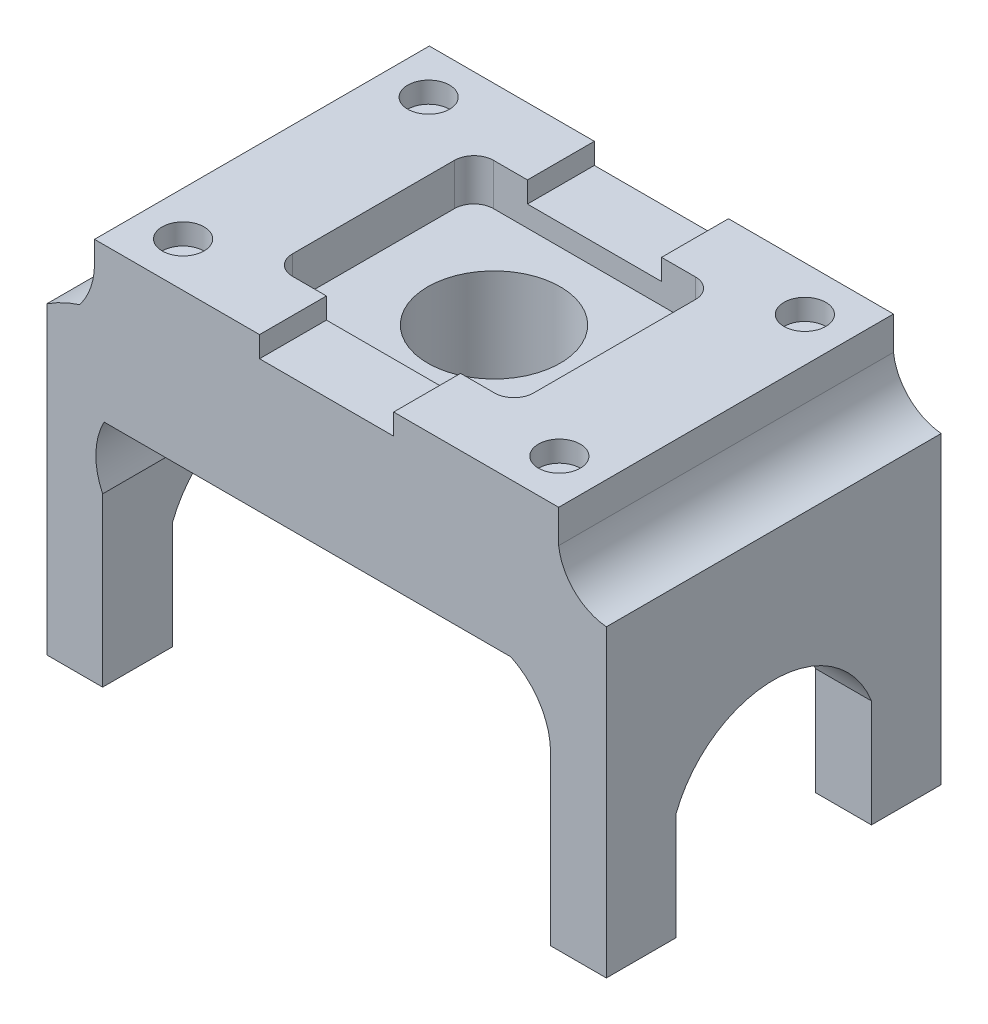
from build123d import *

# Parameters (mm, degrees)
BOSS_EXTRUDE1_DEPTH     = 60.96
SKETCH4_R               = 12.065
CUT_EXTRUDE3_DEPTH      = 3.81
CUT_EXTRUDE4_DEPTH      = 1
CUT_EXTRUDE4_DEPTH_BACK = 102.872142857
SKETCH7_R               = 3.81
BOSS_EXTRUDE3_DEPTH     = 3.81
CUT_EXTRUDE7_DEPTH      = 3.81
SKETCH11_R              = 12.065
CUT_EXTRUDE8_DEPTH      = 114.3


with BuildPart() as part:
    # Sketch1 → Boss-Extrude1 (new body)
    with BuildSketch(Plane.XY):
        with BuildLine():
            Line((40.776071429, -15.784285714), (40.776071429, 14.695714286))
            ThreePointArc((40.776071429, 14.695714286), (38.819326582, 21.468636013), (33.552060607, 26.154490072))
            Line((33.552060607, 26.154490072), (-40.503928571, 26.154490072))
            ThreePointArc((-40.503928571, 26.154490072), (-42.006230477, 20.457549787), (-40.776071429, 14.695714286))
            Line((-40.776071429, 14.695714286), (-40.776071429, -15.784285714))
            Line((-40.776071429, -15.784285714), (-50.936071429, -15.784285714))
            Line((-50.936071429, -15.784285714), (-50.936071429, 39.587714286))
            ThreePointArc((-50.936071429, 39.587714286), (-48.041649354, 41.212124157), (-44.960126074, 42.445250611))
            ThreePointArc((-44.960126074, 42.445250611), (-42.948064089, 46.137564922), (-42.251938956, 50.284490072))
            Line((-42.251938956, 50.284490072), (-29.309810678, 50.284490072))
            Line((-29.309810678, 50.284490072), (29.309810678, 50.284490072))
            Line((29.309810678, 50.284490072), (42.251938956, 50.284490072))
            Line((42.251938956, 50.284490072), (42.251938956, 48.042823233))
            ThreePointArc((42.251938956, 48.042823233), (45.101391865, 42.282225017), (50.936071429, 39.587714286))
            Line((50.936071429, 39.587714286), (50.936071429, -15.784285714))
            Line((50.936071429, -15.784285714), (40.776071429, -15.784285714))
        make_face()
    extrude(amount=BOSS_EXTRUDE1_DEPTH)

    # Sketch4 → Cut-Extrude3 (cut)
    with BuildSketch(Plane(origin=(0, 46.474490072, 0), x_dir=(1, 0, 0), z_dir=(0, 1, 0))):
        with Locations((0, -30.48)):
            Circle(SKETCH4_R)
    extrude(amount=-CUT_EXTRUDE3_DEPTH, mode=Mode.SUBTRACT)

    # Sketch6 → Cut-Extrude4 (cut, two sides)
    with BuildSketch(Plane(origin=(50.936071429, 0, 0), x_dir=(0, 0, -1), z_dir=(1, 0, 0))) as cut_extrude4_sk:
        with BuildLine():
            Line((-48.26, 3.773714286), (-48.26, -15.784285714))
            Line((-48.26, -15.784285714), (-12.7, -15.784285714))
            Line((-12.7, -15.784285714), (-12.7, 3.773714286))
            ThreePointArc((-12.7, 3.773714286), (-30.48, 15.984554981), (-48.26, 3.773714286))
        make_face()
    extrude(amount=CUT_EXTRUDE4_DEPTH, mode=Mode.SUBTRACT)
    extrude(cut_extrude4_sk.sketch, amount=-CUT_EXTRUDE4_DEPTH_BACK, mode=Mode.SUBTRACT)

    # Sketch7 → Boss-Extrude3 (add)
    with BuildSketch(Plane(origin=(0, 50.284490072, 0), x_dir=(1, 0, 0), z_dir=(0, 1, 0))):
        with BuildLine():
            Line((-12.20867372, -12.182150361), (-12.20867372, 0))
            Line((-12.20867372, 0), (-42.251938956, 0))
            Line((-42.251938956, 0), (-42.251938956, -60.96))
            Line((-42.251938956, -60.96), (-12.20867372, -60.96))
            Line((-12.20867372, -60.96), (-12.20867372, -48.777849639))
            Line((-12.20867372, -48.777849639), (-18.390263021, -48.777849639))
            ThreePointArc((-18.390263021, -48.777849639), (-20.904734735, -47.736321353), (-21.946263021, -45.221849639))
            Line((-21.946263021, -45.221849639), (-21.946263021, -15.738150361))
            ThreePointArc((-21.946263021, -15.738150361), (-20.904734735, -13.223678647), (-18.390263021, -12.182150361))
            Line((-18.390263021, -12.182150361), (-12.20867372, -12.182150361))
        make_face()
        with Locations((-34.250938956, -52.832)):
            Circle(SKETCH7_R, mode=Mode.SUBTRACT)
        with Locations((-34.250938956, -8.128)):
            Circle(SKETCH7_R, mode=Mode.SUBTRACT)
        with BuildLine():
            Line((42.251938956, 0), (12.20867372, 0))
            Line((12.20867372, 0), (12.20867372, -12.182150361))
            Line((12.20867372, -12.182150361), (18.390263021, -12.182150361))
            ThreePointArc((18.390263021, -12.182150361), (20.904734735, -13.223678647), (21.946263021, -15.738150361))
            Line((21.946263021, -15.738150361), (21.946263021, -45.221849639))
            ThreePointArc((21.946263021, -45.221849639), (20.904734735, -47.736321353), (18.390263021, -48.777849639))
            Line((18.390263021, -48.777849639), (12.20867372, -48.777849639))
            Line((12.20867372, -48.777849639), (12.20867372, -60.96))
            Line((12.20867372, -60.96), (42.251938956, -60.96))
            Line((42.251938956, -60.96), (42.251938956, 0))
        make_face()
        with Locations((34.250938956, -52.832)):
            Circle(SKETCH7_R, mode=Mode.SUBTRACT)
        with Locations((34.250938956, -8.128)):
            Circle(SKETCH7_R, mode=Mode.SUBTRACT)
    extrude(amount=BOSS_EXTRUDE3_DEPTH)

    # Sketch8 → Cut-Extrude7 (cut)
    with BuildSketch(Plane(origin=(0, 50.284490072, 0), x_dir=(1, 0, 0), z_dir=(0, 1, 0))):
        Polygon((-12.20867372, -12.182150361), (-18.390263021, -12.182150361), (-18.390263021, -48.777849639), (-12.20867372, -48.777849639), (12.20867372, -48.777849639), (18.390263021, -48.777849639), (18.390263021, -12.182150361), (12.20867372, -12.182150361), align=None)
        with BuildLine():
            Line((-18.390263021, -12.182150361), (-18.390263021, -48.777849639))
            ThreePointArc((-18.390263021, -48.777849639), (-20.904734735, -47.736321353), (-21.946263021, -45.221849639))
            Line((-21.946263021, -45.221849639), (-21.946263021, -15.738150361))
            ThreePointArc((-21.946263021, -15.738150361), (-20.904734735, -13.223678647), (-18.390263021, -12.182150361))
        make_face()
        with BuildLine():
            Line((18.390263021, -12.182150361), (18.390263021, -48.777849639))
            ThreePointArc((18.390263021, -48.777849639), (20.904734735, -47.736321353), (21.946263021, -45.221849639))
            Line((21.946263021, -45.221849639), (21.946263021, -15.738150361))
            ThreePointArc((21.946263021, -15.738150361), (20.904734735, -13.223678647), (18.390263021, -12.182150361))
        make_face()
    extrude(amount=-CUT_EXTRUDE7_DEPTH, mode=Mode.SUBTRACT)

    # Sketch11 → Cut-Extrude8 (cut)
    with BuildSketch(Plane(origin=(0, 0, 0), x_dir=(1, 0, 0), z_dir=(0, 1, 0))):
        with Locations((0, -30.48)):
            Circle(SKETCH11_R)
    extrude(amount=CUT_EXTRUDE8_DEPTH, mode=Mode.SUBTRACT)


solid = part.part
